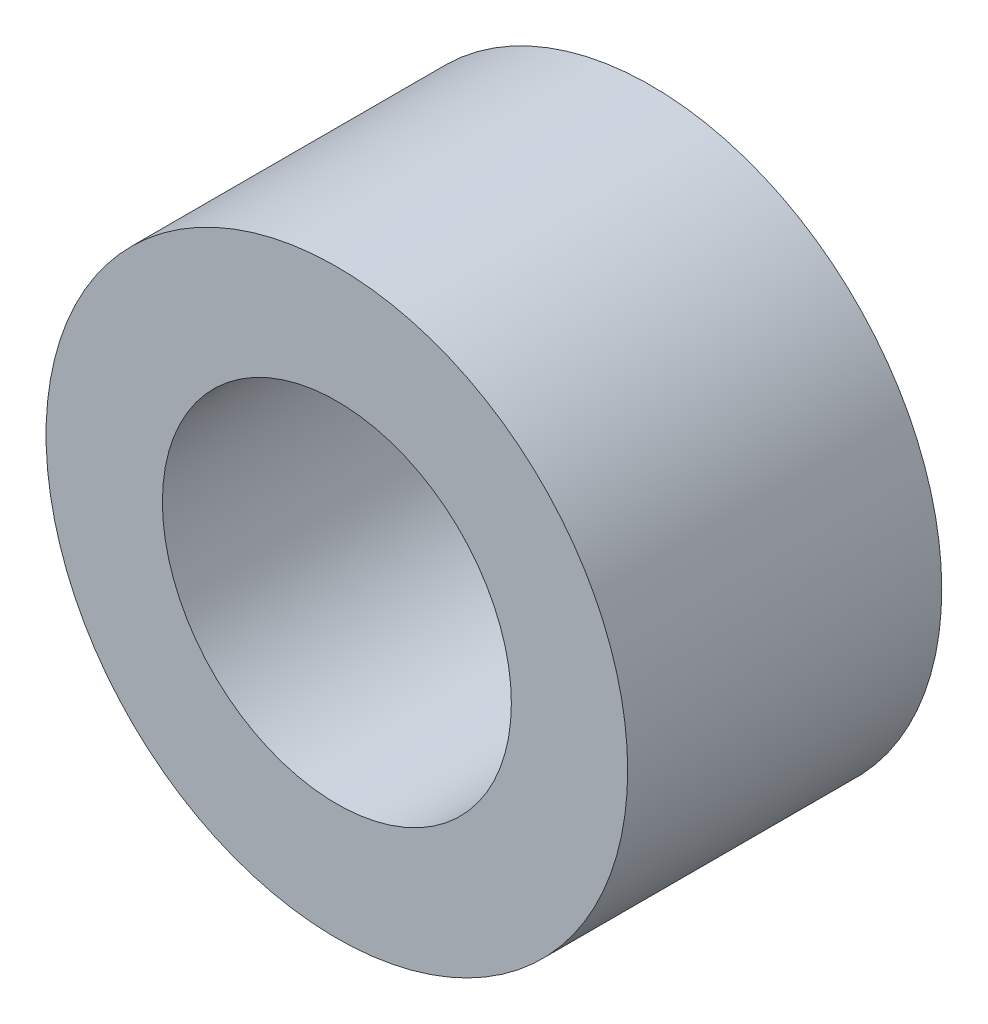
from build123d import *

# Parameters (mm, degrees)
SKETCH_1_R      = 5
SKETCH_1_R_2    = 3
EXTRUDE_1_DEPTH = 5.4


with BuildPart() as part:
    # ｽｹｯﾁ1 → ﾎﾞｽ - 押し出し1 (new body)
    with BuildSketch(Plane.XY):
        Circle(SKETCH_1_R)
        Circle(SKETCH_1_R_2, mode=Mode.SUBTRACT)
    extrude(amount=EXTRUDE_1_DEPTH)


solid = part.part
